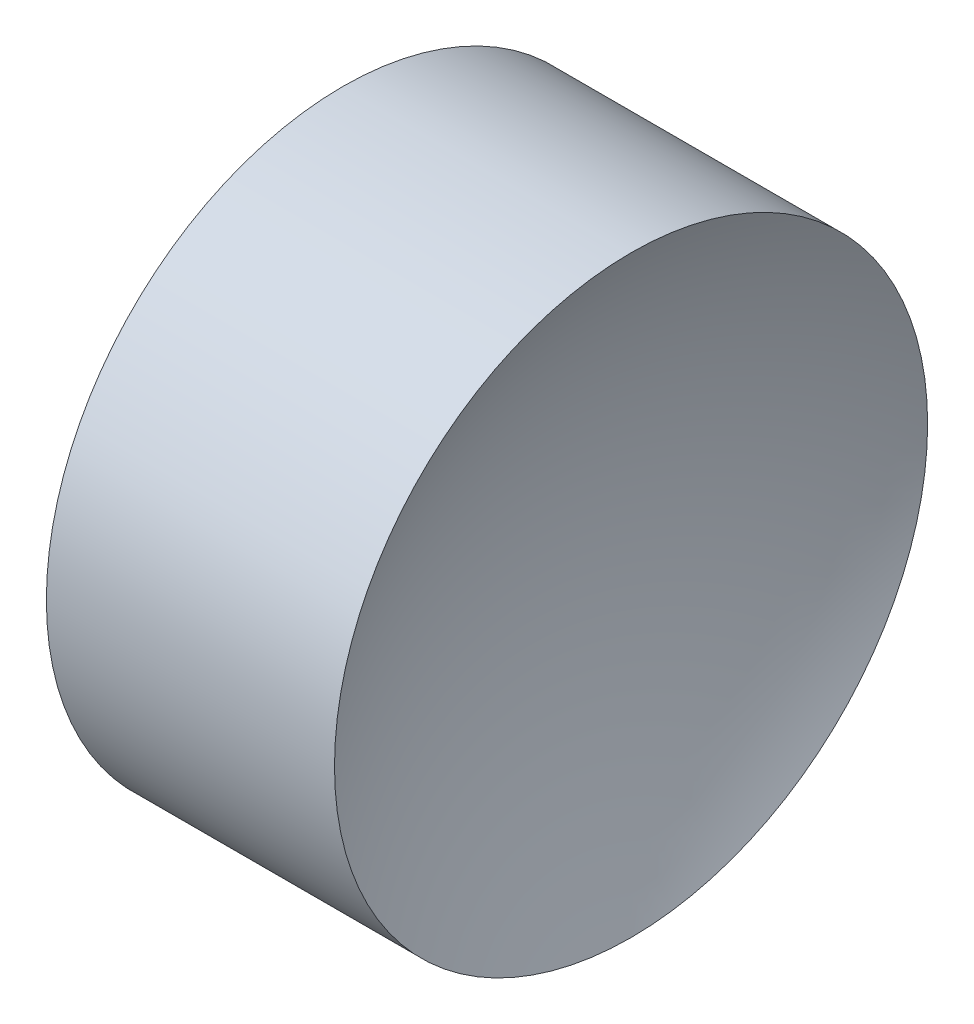
from build123d import *


with BuildPart() as part:
    # 草图2 → 旋转1 (revolve)
    with BuildSketch(Plane.XY):
        with BuildLine():
            Line((23.261852872, 13.044520575), (24.761852872, 13.044520575))
            ThreePointArc((24.761852872, 13.044520575), (24.959773385, 14.667097044), (25.541928249, 16.194520575))
            Line((25.541928249, 16.194520575), (24.011852872, 16.194520575))
            Line((24.011852872, 16.194520575), (22.481777494, 16.194520575))
            ThreePointArc((22.481777494, 16.194520575), (23.063932359, 14.667097044), (23.261852872, 13.044520575))
        make_face()
    revolve(axis=Axis((21.224930557, 13.044520575, 0), (1, 0, 0)))


solid = part.part
